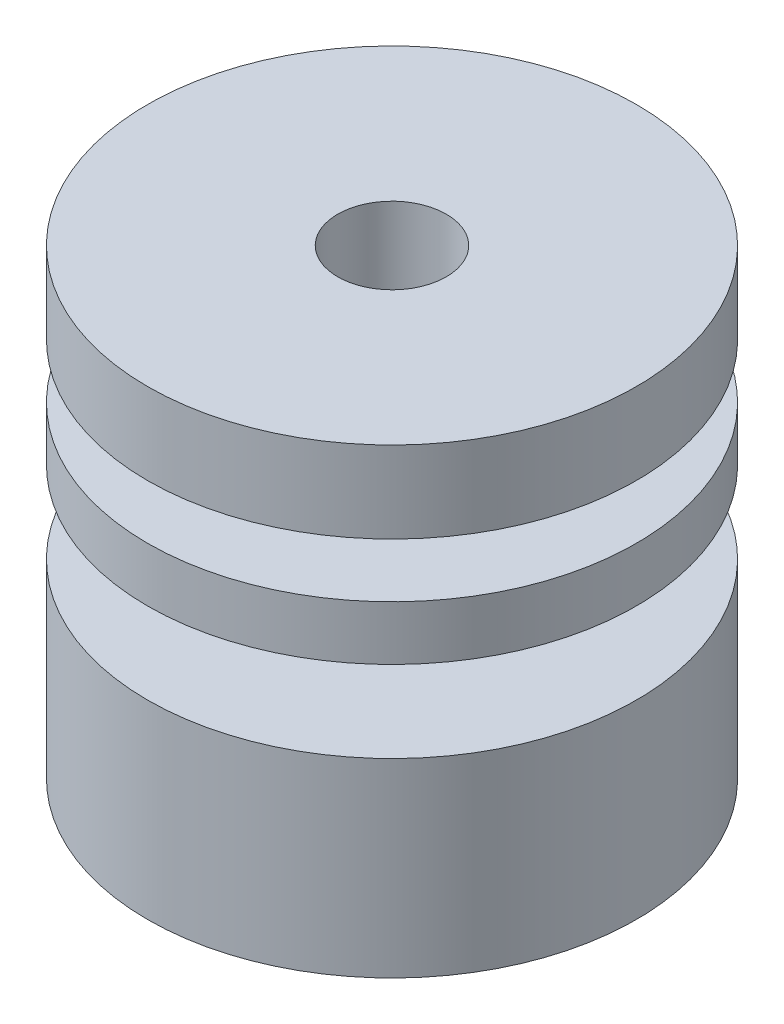
from build123d import *

# Parameters (mm, degrees)
SKETCH1_W   = 6.5
SKETCH1_H   = 3
SKETCH1_H_2 = 2
SKETCH1_H_3 = 7
SKETCH1_W_2 = 2


with BuildPart() as part:
    # Sketch1 → Revolve1 (revolve)
    with BuildSketch(Plane.XY):
        Polygon((2, 0), (2.5, 0), (2.5, 7), (2.5, 10), (2.5, 12), (2.5, 14), (2.5, 17), (2, 17), align=None)
        with Locations((5.75, 15.5)):
            Rectangle(SKETCH1_W, SKETCH1_H)
        with Locations((5.75, 11)):
            Rectangle(SKETCH1_W, SKETCH1_H_2)
        with Locations((5.75, 3.5)):
            Rectangle(SKETCH1_W, SKETCH1_H_3)
        with Locations((3.5, 8.5)):
            Rectangle(SKETCH1_W_2, SKETCH1_H)
        with Locations((3.5, 13)):
            Rectangle(SKETCH1_W_2, SKETCH1_H_2)
    revolve(axis=Axis((0, 0, 0), (0, 1, 0)))


solid = part.part
